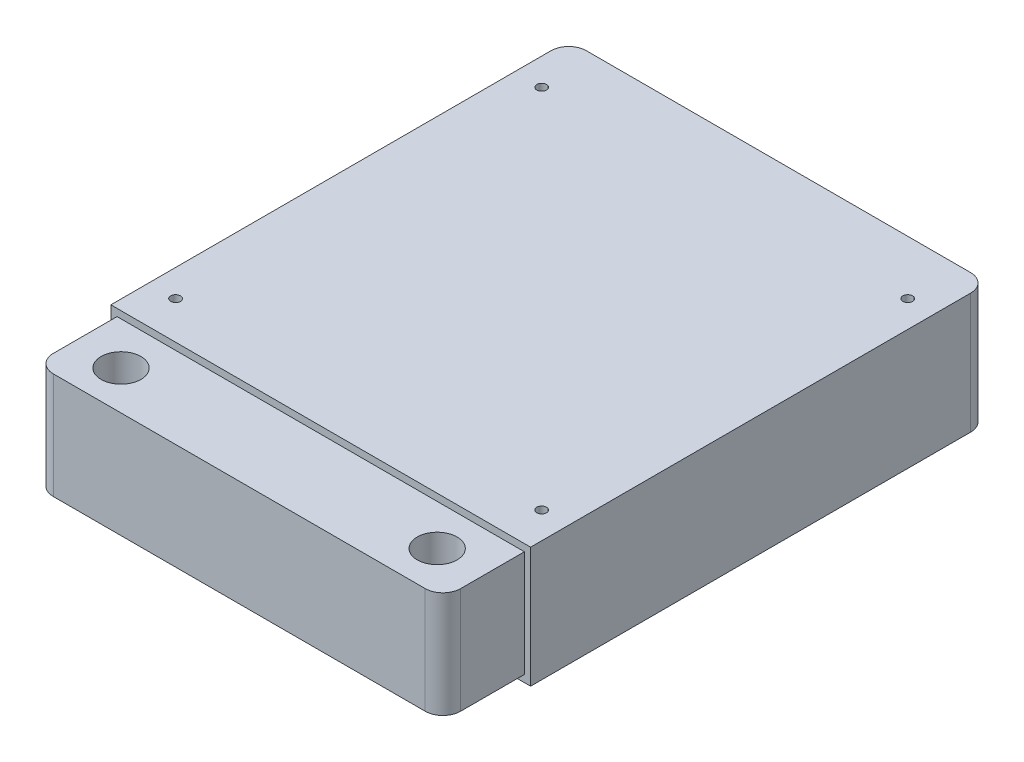
from build123d import *

# Parameters (mm, degrees)
SKETCH1_W           = 120.396
SKETCH1_H           = 131.318
BOSS_EXTRUDE1_DEPTH = 34.544
SKETCH2_R           = 1.397
CUT_EXTRUDE1_DEPTH  = 35.544
SKETCH3_W           = 116.84
SKETCH3_H           = 30.48
BOSS_EXTRUDE2_DEPTH = 23.368
SKETCH4_R           = 5.715
CUT_EXTRUDE2_DEPTH  = 33.512
FILLET1_R           = 5.08


with BuildPart() as part:
    # Sketch1 → Boss-Extrude1 (new body)
    with BuildSketch(Plane(origin=(0, 0, 0), x_dir=(1, 0, 0), z_dir=(0, 1, 0))):
        with Locations((-83.235647386, 53.565832685)):
            Rectangle(SKETCH1_W, SKETCH1_H)
    extrude(amount=BOSS_EXTRUDE1_DEPTH)

    # Sketch2 → Cut-Extrude1 (cut, through all)
    with BuildSketch(Plane(origin=(0, 34.544, 0), x_dir=(1, 0, 0), z_dir=(0, 1, 0))):
        with Locations((-135.686647386, 103.730832685)):
            Circle(SKETCH2_R)
        with Locations((-30.686647386, 103.730832685)):
            Circle(SKETCH2_R)
        with Locations((-135.686647386, -1.269167315)):
            Circle(SKETCH2_R)
        with Locations((-30.686647328, -1.269167315)):
            Circle(SKETCH2_R)
    extrude(amount=-CUT_EXTRUDE1_DEPTH, mode=Mode.SUBTRACT)

    # Sketch3 → Boss-Extrude2 (add)
    with BuildSketch(Plane.XY.offset(12.093167315)):
        with Locations((-83.235647386, 17.272)):
            Rectangle(SKETCH3_W, SKETCH3_H)
    extrude(amount=BOSS_EXTRUDE2_DEPTH)

    # Sketch4 → Cut-Extrude2 (cut, through all)
    with BuildSketch(Plane(origin=(0, 32.512, 0), x_dir=(1, 0, 0), z_dir=(0, 1, 0))):
        with Locations((-128.320647386, -24.288198654)):
            Circle(SKETCH4_R)
        with Locations((-38.150647386, -23.777167315)):
            Circle(SKETCH4_R)
    extrude(amount=-CUT_EXTRUDE2_DEPTH, mode=Mode.SUBTRACT)

    # Fillet1
    fillet1_edges = [part.edges().sort_by_distance(p)[0] for p in [
        (-24.815647386, 17.272, 35.461167315),
        (-141.655647386, 17.272, 35.461167315),
        (-143.433647386, 17.272, -119.224832685),
        (-23.037647386, 17.272, -119.224832685),
    ]]
    fillet(fillet1_edges, radius=FILLET1_R)


solid = part.part
